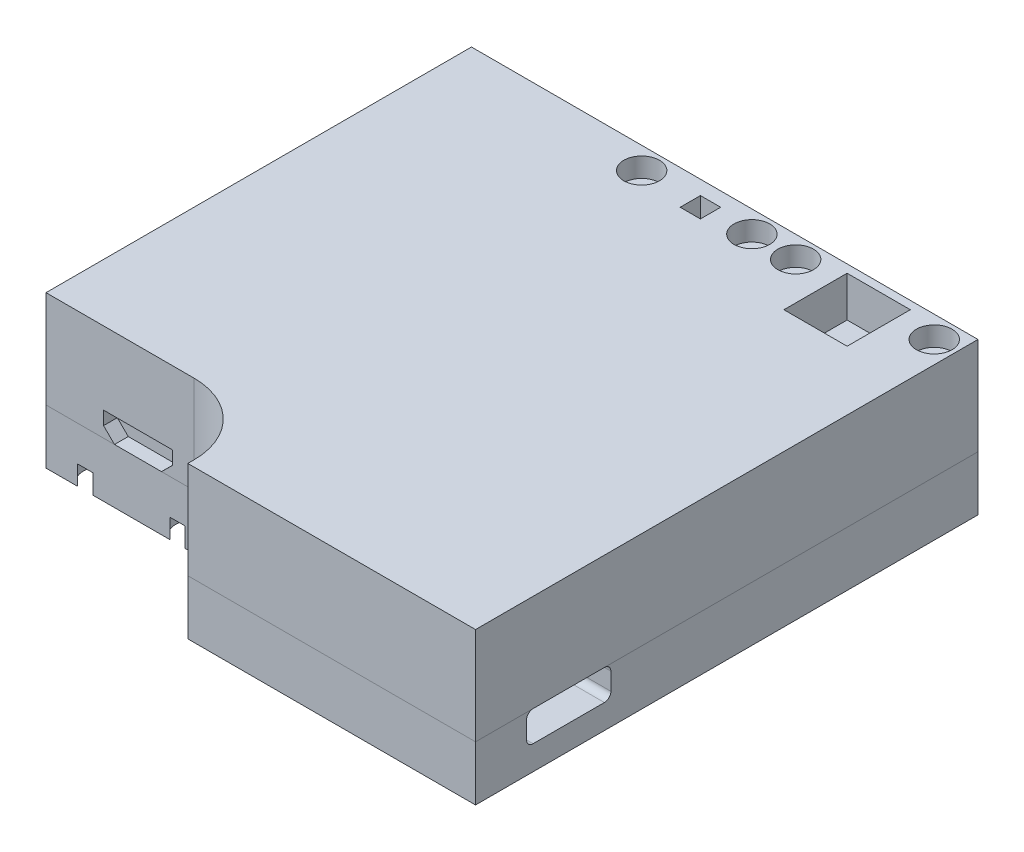
from build123d import *

# Parameters (mm, degrees)
BOSS_EXTRUDE1_DEPTH                                 = 12
BOSS_EXTRUDE1_DEPTH_BACK                            = 6.75
SKETCH5_W                                           = 7.8
SKETCH5_H                                           = 7.8
SKETCH5_W_2                                         = 2.5
SKETCH5_H_2                                         = 2.5
CUT_EXTRUDE1_DEPTH                                  = 5
SKETCH17_W                                          = 10.4
SKETCH17_H                                          = 3.75
CUT_EXTRUDE2_DEPTH                                  = 5
FILLET6_R                                           = 0.8
CUT_EXTRUDE3_DEPTH                                  = 1.7
FILLET4_R                                           = 8.75
CBORE_FOR_M2_HEX_SOCKET_HEAD_CAP_SCREW1_D           = 2.4
CBORE_FOR_M2_HEX_SOCKET_HEAD_CAP_SCREW1_DEPTH       = 14
CBORE_FOR_M2_HEX_SOCKET_HEAD_CAP_SCREW1_CBORE_D     = 4.4
CBORE_FOR_M2_HEX_SOCKET_HEAD_CAP_SCREW1_CBORE_DEPTH = 2.4
CBORE_FOR_M2_HEX_SOCKET_HEAD_CAP_SCREW2_D           = 2.4
CBORE_FOR_M2_HEX_SOCKET_HEAD_CAP_SCREW2_DEPTH       = 14
CBORE_FOR_M2_HEX_SOCKET_HEAD_CAP_SCREW2_CBORE_D     = 4.4
CBORE_FOR_M2_HEX_SOCKET_HEAD_CAP_SCREW2_CBORE_DEPTH = 2.4


with BuildPart() as part:
    # Sketch2 → Boss-Extrude1 (new body, two sides)
    with BuildSketch(Plane(origin=(0, 0, 0), x_dir=(1, 0, 0), z_dir=(0, 1, 0))) as boss_extrude1_sk:
        Polygon((-35.5, 9.5), (-62.5, 9.5), (-62.5, 62), (0, 62), (0, 0), (-35.5, 0), align=None)
    extrude(amount=BOSS_EXTRUDE1_DEPTH)
    extrude(boss_extrude1_sk.sketch, amount=-BOSS_EXTRUDE1_DEPTH_BACK)

    # Sketch5 → Cut-Extrude1 (cut, symmetric)
    with BuildSketch(Plane(origin=(0, 12, 0), x_dir=(1, 0, 0), z_dir=(0, 1, 0))):
        with Locations((-11.25, 57.1)):
            Rectangle(SKETCH5_W, SKETCH5_H)
        with Locations((-31.25, 59)):
            Rectangle(SKETCH5_W_2, SKETCH5_H_2)
    extrude(amount=CUT_EXTRUDE1_DEPTH, both=True, mode=Mode.SUBTRACT)

    # Sketch17 → Cut-Extrude2 (cut, symmetric)
    with BuildSketch(Plane(origin=(0, 0, 0), x_dir=(0, 0, -1), z_dir=(1, 0, 0))):
        with Locations((11.5, -1.875)):
            Rectangle(SKETCH17_W, SKETCH17_H)
    extrude(amount=CUT_EXTRUDE2_DEPTH, both=True, mode=Mode.SUBTRACT)

    # Fillet6
    fillet6_edges = [part.edges().sort_by_distance(p)[0] for p in [
        (-2.5, 0, -16.7),
        (-2.5, 0, -6.3),
        (-2.5, -3.75, -16.7),
        (-2.5, -3.75, -6.3),
    ]]
    fillet(fillet6_edges, radius=FILLET6_R)

    # Sketch20 → Cut-Extrude3 (cut, symmetric)
    with BuildSketch(Plane.XY.offset(-9.5)):
        Polygon((-52, 3), (-55.4, 3), (-55.4, 1.34), (-54.05, 0), (-52, 0), align=None)
        Polygon((-46.9, 3), (-52, 3), (-52, 0), (-48.25, 0), (-46.9, 1.34), align=None)
    extrude(amount=CUT_EXTRUDE3_DEPTH, both=True, mode=Mode.SUBTRACT)

    # Fillet4
    fillet4_edges = [part.edges().sort_by_distance(p)[0] for p in [
        (-35.5, 2.625, -9.5),
    ]]
    fillet(fillet4_edges, radius=FILLET4_R)

    # CBORE for M2 Hex Socket Head Cap Screw1
    with Locations(Plane(origin=(-2.7, 12, -59.3), x_dir=(0, 0, 1), z_dir=(0, 1, 0))):
        with Locations((0, 0), (0, -17.1), (0, -22.5), (0, -36.1)):
            CounterBoreHole(CBORE_FOR_M2_HEX_SOCKET_HEAD_CAP_SCREW1_D / 2, CBORE_FOR_M2_HEX_SOCKET_HEAD_CAP_SCREW1_CBORE_D / 2, CBORE_FOR_M2_HEX_SOCKET_HEAD_CAP_SCREW1_CBORE_DEPTH, depth=CBORE_FOR_M2_HEX_SOCKET_HEAD_CAP_SCREW1_DEPTH)

    # CBORE for M2 Hex Socket Head Cap Screw2
    with Locations(Plane(origin=(-57.743552304, -6.75, -60.036040553), x_dir=(0, 0, -1), z_dir=(0, -1, 0))):
        with Locations((0, 0), (-0.03018486, 11.449075617), (-48.546711763, 11.455424933), (-48.559690268, 0.06838538), (-57.522654137, 25.243612903), (-57.536346288, 55.243791663), (-39.535169759, 55.244781727)):
            CounterBoreHole(CBORE_FOR_M2_HEX_SOCKET_HEAD_CAP_SCREW2_D / 2, CBORE_FOR_M2_HEX_SOCKET_HEAD_CAP_SCREW2_CBORE_D / 2, CBORE_FOR_M2_HEX_SOCKET_HEAD_CAP_SCREW2_CBORE_DEPTH, depth=CBORE_FOR_M2_HEX_SOCKET_HEAD_CAP_SCREW2_DEPTH)


with BuildPart() as body_2:
    # Split1: the piece on the far side of the plane
    add(part.part)
    split(bisect_by=Plane.ZX, keep=Keep.BOTTOM)


with BuildPart() as part_1:
    add(part.part)

    # Split1
    split(bisect_by=Plane.ZX, keep=Keep.TOP)


solid = Compound([body_2.part, part_1.part])
